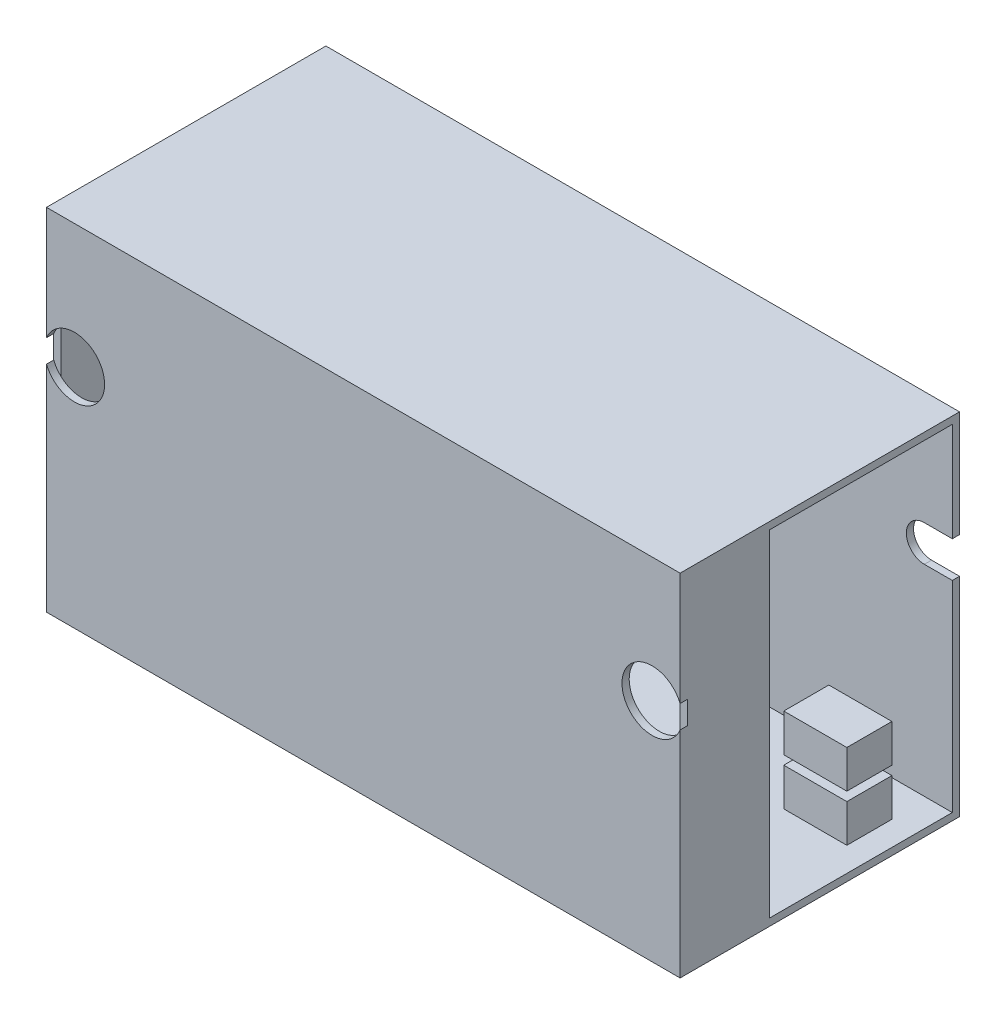
from build123d import *

# Parameters (mm, degrees)
SKETCH1_W        = 70.3
SKETCH1_H        = 38.9
EXTRUDE1_DEPTH   = 31
SKETCH2_W        = 20.3
SKETCH2_H        = 37.3
EXTRUDE2_DEPTH   = 71.3
SKETCH3_W        = 68.7
SKETCH3_H        = 37.3
EXTRUDE3_DEPTH   = 9.1
EXTRUDE4_DEPTH   = 0.8
SKETCH5_R        = 3.35
EXTRUDE5_DEPTH   = 0.8
SKETCH6_W        = 5
SKETCH6_H        = 4.2
EXTRUDE6_DEPTH   = 7
EXTRUDE6_2_DEPTH = 7
EXTRUDE6_3_DEPTH = 7
SKETCH7_W        = 5
SKETCH7_H        = 4.2
EXTRUDE7_DEPTH   = 7
EXTRUDE7_2_DEPTH = 7


with BuildPart() as part:
    # Sketch1 → Extrude1 (new body)
    with BuildSketch(Plane.XY):
        Rectangle(SKETCH1_W, SKETCH1_H)
    extrude(amount=EXTRUDE1_DEPTH)

    # Sketch2 → Extrude2 (cut, through all)
    with BuildSketch(Plane(origin=(35.15, 0, 0), x_dir=(0, 0, -1), z_dir=(1, 0, 0))):
        with Locations((-10.95, 0)):
            Rectangle(SKETCH2_W, SKETCH2_H)
    extrude(amount=-EXTRUDE2_DEPTH, mode=Mode.SUBTRACT)

    # Sketch3 → Extrude3 (cut)
    with BuildSketch(Plane(origin=(0, 0, 21.1), x_dir=(-1, 0, 0), z_dir=(0, 0, -1))):
        Rectangle(SKETCH3_W, SKETCH3_H)
    extrude(amount=-EXTRUDE3_DEPTH, mode=Mode.SUBTRACT)

    # Sketch4 → Extrude4 (cut)
    with BuildSketch(Plane.XY.offset(0.8)):
        with BuildLine():
            Line((32.05, 7.65), (35.15, 7.65))
            Line((35.15, 7.65), (35.15, 3.65))
            Line((35.15, 3.65), (32.05, 3.65))
            ThreePointArc((32.05, 3.65), (30.05, 5.65), (32.05, 7.65))
        make_face()
        with BuildLine():
            Line((-35.15, 7.65), (-32.05, 7.65))
            ThreePointArc((-32.05, 7.65), (-30.05, 5.65), (-32.05, 3.65))
            Line((-32.05, 3.65), (-35.15, 3.65))
            Line((-35.15, 3.65), (-35.15, 7.65))
        make_face()
    extrude(amount=-EXTRUDE4_DEPTH, mode=Mode.SUBTRACT)

    # Sketch5 → Extrude5 (cut)
    with BuildSketch(Plane.XY.offset(31)):
        with Locations((32.05, 5.65)):
            Circle(SKETCH5_R)
        with Locations((-32.05, 5.65)):
            Circle(SKETCH5_R)
    extrude(amount=-EXTRUDE5_DEPTH, mode=Mode.SUBTRACT)


with BuildPart() as body_2:
    # Sketch6 → Extrude6 (new body)
    with BuildSketch(Plane.ZY.offset(35.15)):
        with Locations((10, -3.45)):
            Rectangle(SKETCH6_W, SKETCH6_H)
    extrude(amount=-EXTRUDE6_DEPTH)


with BuildPart() as body_3:
    # Sketch6 → Extrude6 2 (new body)
    with BuildSketch(Plane.ZY.offset(35.15)):
        with Locations((10, -8.65)):
            Rectangle(SKETCH6_W, SKETCH6_H)
    extrude(amount=-EXTRUDE6_2_DEPTH)


with BuildPart() as body_4:
    # Sketch6 → Extrude6 3 (new body)
    with BuildSketch(Plane.ZY.offset(35.15)):
        with Locations((10, -13.85)):
            Rectangle(SKETCH6_W, SKETCH6_H)
    extrude(amount=-EXTRUDE6_3_DEPTH)


with BuildPart() as body_5:
    # Sketch7 → Extrude7 (new body)
    with BuildSketch(Plane(origin=(35.15, 0, 0), x_dir=(0, 0, -1), z_dir=(1, 0, 0))):
        with Locations((-10, -8.65)):
            Rectangle(SKETCH7_W, SKETCH7_H)
    extrude(amount=-EXTRUDE7_DEPTH)


with BuildPart() as body_6:
    # Sketch7 → Extrude7 2 (new body)
    with BuildSketch(Plane(origin=(35.15, 0, 0), x_dir=(0, 0, -1), z_dir=(1, 0, 0))):
        with Locations((-10, -13.85)):
            Rectangle(SKETCH7_W, SKETCH7_H)
    extrude(amount=-EXTRUDE7_2_DEPTH)


solid = Compound([part.part, body_2.part, body_3.part, body_4.part, body_5.part, body_6.part])
